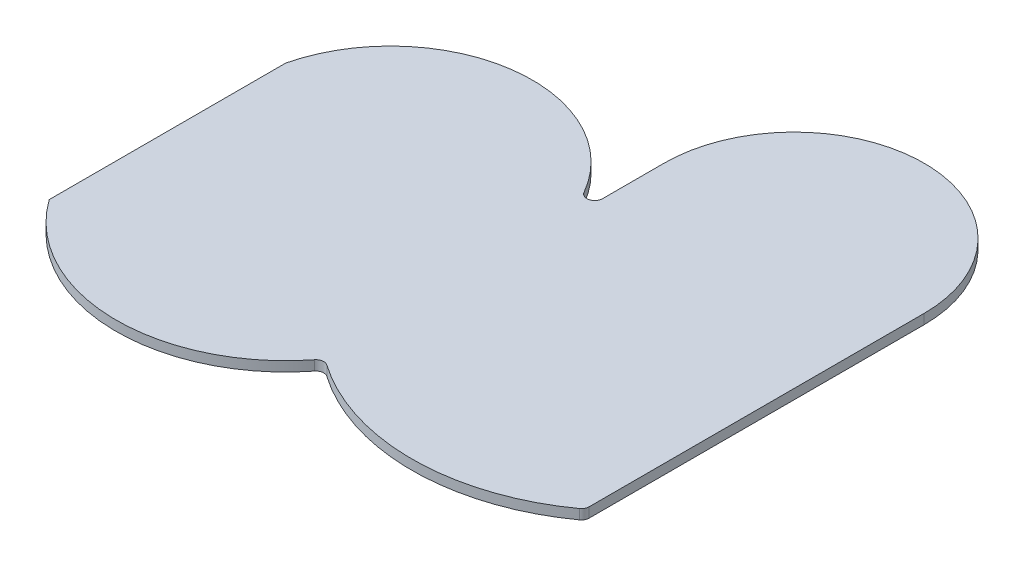
from build123d import *

# Parameters (mm, degrees)
BOSS_EXTRUDE1_DEPTH = 6.25
FILLET1_R           = 10


with BuildPart() as part:
    # Sketch2 → Boss-Extrude1 (new body, symmetric)
    with BuildSketch(Plane(origin=(0, 0, 0), x_dir=(1, 0, 0), z_dir=(0, 1, 0))):
        with BuildLine():
            Line((-515, 150), (-515, -150))
            ThreePointArc((-515, -150), (-340, -240), (-165, -150))
            ThreePointArc((-165, -150), (0, -205), (165, -150))
            Line((165, -150), (165, 150))
            Line((165, 150), (165, 280))
            ThreePointArc((165, 280), (0, 445), (-165, 280))
            Line((-165, 280), (-165, 150))
            ThreePointArc((-165, 150), (-340, 287.869251134), (-515, 150))
        make_face()
    extrude(amount=BOSS_EXTRUDE1_DEPTH, both=True)

    # Fillet1
    fillet1_edges = [part.edges().sort_by_distance(p)[0] for p in [
        (-165, 0, 150),
        (-165, 0, -150),
        (165, 0, 150),
    ]]
    fillet(fillet1_edges, radius=FILLET1_R)


solid = part.part
